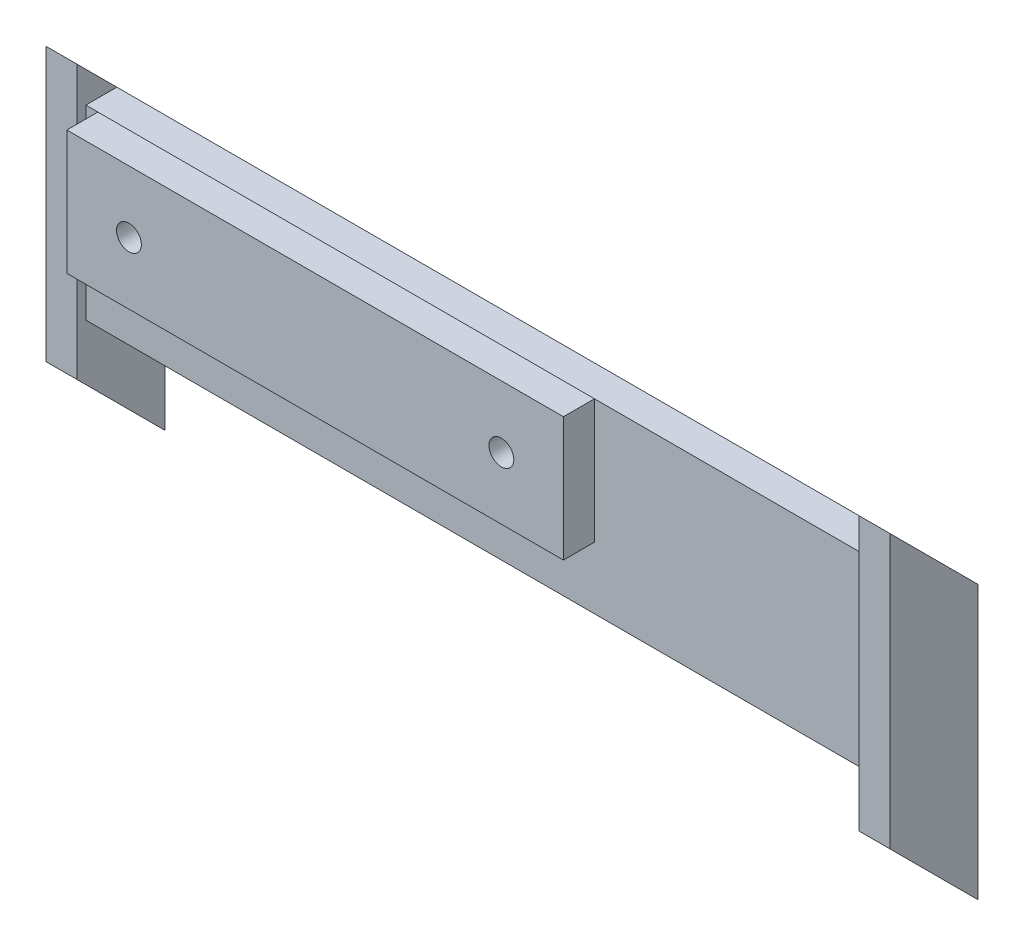
from build123d import *

# Parameters (mm, degrees)
SKETCH1_W            = 80
SKETCH1_H            = 20
SKETCH1_R            = 2
BOSS_EXTRUDE1_DEPTH  = 5
BOSS_EXTRUDE2_DEPTH  = 5
BOSS_EXTRUDE3_DEPTH  = 5
BOSS_EXTRUDE4_DEPTH  = 5
BOSS_EXTRUDE9_DEPTH  = 5
BOSS_EXTRUDE10_DEPTH = 5


with BuildPart() as part:
    # Sketch1 → Boss-Extrude1 (new body)
    with BuildSketch(Plane.XY):
        with Locations((0.15936255, 5.458167331)):
            Rectangle(SKETCH1_W, SKETCH1_H)
        with Locations((-29.84063745, 5.458167331)):
            Circle(SKETCH1_R, mode=Mode.SUBTRACT)
        with Locations((30.15936255, 5.458167331)):
            Circle(SKETCH1_R, mode=Mode.SUBTRACT)
    extrude(amount=BOSS_EXTRUDE1_DEPTH)

    # Sketch2 → Boss-Extrude2 (add)
    with BuildSketch(Plane(origin=(12, 0, 0), x_dir=(0, 0, -1), z_dir=(1, 0, 0))):
        Polygon((0, 15.458167331), (21.213203436, -5.755036105), (21.213203436, -25.755036105), (0, -4.541832669), align=None)
    extrude(amount=BOSS_EXTRUDE2_DEPTH)

    # Sketch3 → Boss-Extrude3 (add)
    with BuildSketch(Plane(origin=(-12, 0, 0), x_dir=(0, 0, -1), z_dir=(1, 0, 0))):
        Polygon((0, 15.458167331), (21.213203436, -5.755036105), (21.213203436, -25.755036105), (0, -4.541832669), align=None)
    extrude(amount=-BOSS_EXTRUDE3_DEPTH)

    # Sketch4 → Boss-Extrude4 (add)
    with BuildSketch(Plane(origin=(0, 0, -21.213203436), x_dir=(-1, 0, 0), z_dir=(0, 0, -1))):
        Polygon((65, -5.755036105), (-17, -5.755036105), (-65, -5.755036105), (-65, -25.127384199), (-65, -32.826103917), (-65, -35.755036105), (65, -35.755036105), (65, -32.826103917), (65, -25.561464244), align=None)
    extrude(amount=BOSS_EXTRUDE4_DEPTH)

    # Sketch6 → Boss-Extrude9 (add)
    with BuildSketch(Plane(origin=(63, 0, 0), x_dir=(0, 0, -1), z_dir=(1, 0, 0))):
        Polygon((26.213203436, -5.755036105), (33.941125497, -13.482958166), (33.941125497, -50.554025978), (33.941125497, -55.554025978), (33.941125497, -57.482958166), (21.213203436, -44.755036105), (19.798989873, -43.340822543), (19.798989873, 0.659177457), (21.213203436, -0.755036105), align=None)
    extrude(amount=BOSS_EXTRUDE9_DEPTH)

    # Sketch8 → Boss-Extrude10 (add)
    with BuildSketch(Plane.ZY.offset(63)):
        Polygon((-19.798989873, 0.659177457), (-33.941125497, -13.482958166), (-33.941125497, -57.482958166), (-19.798989873, -43.340822543), align=None)
    extrude(amount=BOSS_EXTRUDE10_DEPTH)


solid = part.part
